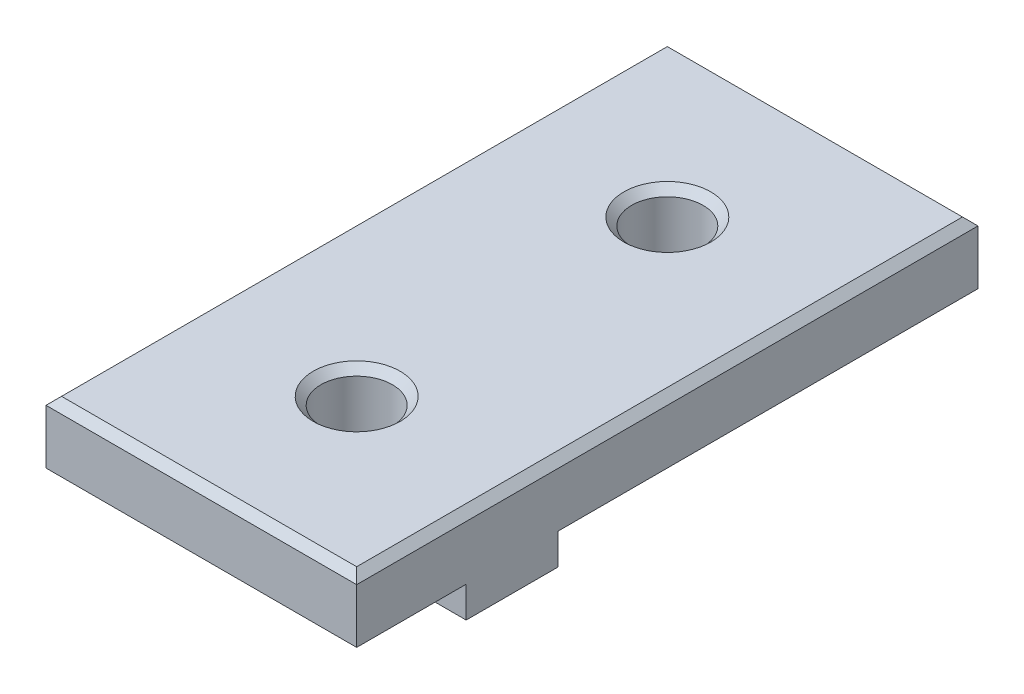
from build123d import *

# Parameters (mm, degrees)
ESBO_O1_W                  = 20
ESBO_O1_H                  = 40
RESSALTO_EXTRUS_O1_DEPTH   = 4
ESBO_O2_R                  = 2.3
CORTE_EXTRUS_O1_DEPTH      = 1
CORTE_EXTRUS_O1_DEPTH_BACK = 5
ESBO_O3_W                  = 5.9
ESBO_O3_H                  = 6
ESBO_O3_H_2                = 7
ESBO_O3_W_2                = 7
ESBO_O3_H_3                = 5.9
RESSALTO_EXTRUS_O2_DEPTH   = 2
CHANFRO1_SIZE              = 0.5


with BuildPart() as part:
    # Esboço1 → Ressalto-extrusão1 (new body)
    with BuildSketch(Plane(origin=(0, 0, 0), x_dir=(1, 0, 0), z_dir=(0, 1, 0))):
        Rectangle(ESBO_O1_W, ESBO_O1_H)
    extrude(amount=RESSALTO_EXTRUS_O1_DEPTH)

    # Esboço2 → Corte-extrusão1 (cut, two sides)
    with BuildSketch(Plane(origin=(0, 4, 0), x_dir=(1, 0, 0), z_dir=(0, 1, 0))) as corte_extrus_o1_sk:
        with Locations((0, 10)):
            Circle(ESBO_O2_R)
        with Locations((0, -10)):
            Circle(ESBO_O2_R)
    extrude(amount=CORTE_EXTRUS_O1_DEPTH, mode=Mode.SUBTRACT)
    extrude(corte_extrus_o1_sk.sketch, amount=-CORTE_EXTRUS_O1_DEPTH_BACK, mode=Mode.SUBTRACT)

    # Esboço3 → Ressalto-extrusão2 (add)
    with BuildSketch(Plane.XZ):
        with Locations((0, -4)):
            Rectangle(ESBO_O3_W, ESBO_O3_H)
        with Locations((0, -16.5)):
            Rectangle(ESBO_O3_W, ESBO_O3_H_2)
        with Locations((-6.5, 10)):
            Rectangle(ESBO_O3_W_2, ESBO_O3_H_3)
        with Locations((6.5, 10)):
            Rectangle(ESBO_O3_W_2, ESBO_O3_H_3)
    extrude(amount=RESSALTO_EXTRUS_O2_DEPTH)

    # Chanfro1
    chanfro1_edges = [part.edges().sort_by_distance(p)[0] for p in [
        (-10, 4, 0),
        (0, 4, 20),
        (-2.3, 4, -10),
        (-2.3, 4, 10),
        (10, 4, 0),
        (0, 4, -20),
    ]]
    chamfer(chanfro1_edges, length=CHANFRO1_SIZE)


solid = part.part
